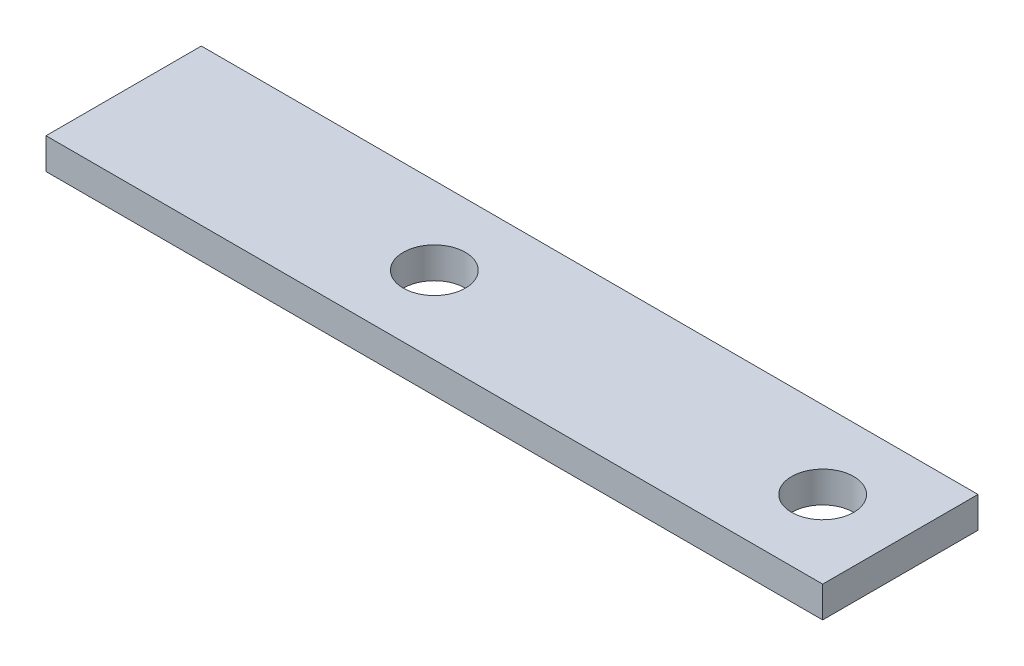
from build123d import *

# Parameters (mm, degrees)
SKETCH_1_W          = 20
SKETCH_1_H          = 4
EXTRUDE_1_DEPTH     = 100
SKETCH_2_R          = 4
CUT_EXTRUDE_1_DEPTH = 5


with BuildPart() as part:
    # Эскиз1 → Вытянуть-Тонкостенный1 (new body)
    with BuildSketch(Plane(origin=(0, 0, 0), x_dir=(0, 0, -1), z_dir=(1, 0, 0))):
        with Locations((10, -2)):
            Rectangle(SKETCH_1_W, SKETCH_1_H)
    extrude(amount=EXTRUDE_1_DEPTH)

    # Эскиз2 → Вырез-Вытянуть1 (cut, through all)
    with BuildSketch(Plane(origin=(0, 0, 0), x_dir=(1, 0, 0), z_dir=(0, 1, 0))):
        with Locations((90, 10)):
            Circle(SKETCH_2_R)
        with Locations((40, 10)):
            Circle(SKETCH_2_R)
    extrude(amount=-CUT_EXTRUDE_1_DEPTH, mode=Mode.SUBTRACT)


solid = part.part
